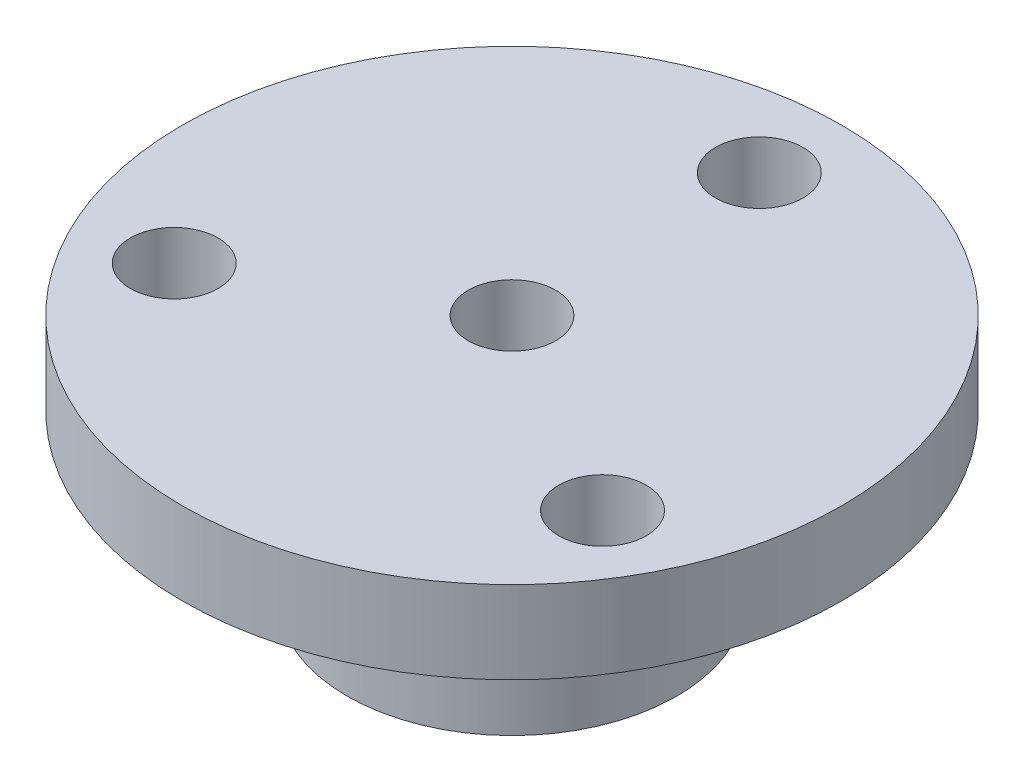
from build123d import *

# Parameters (mm, degrees)
SKETCH1_R                    = 12.7
BOSS_EXTRUDE1_DEPTH          = 12.7
SKETCH2_R                    = 25.4
BOSS_EXTRUDE2_DEPTH          = 6.35
SKETCH3_R                    = 3.3734375
CUT_EXTRUDE1_DEPTH           = 20.05
H_0_266_DIAMETER_HOLE1_D     = 6.7564
H_0_266_DIAMETER_HOLE1_DEPTH = 25.4
H_0_266_DIAMETER_HOLE1_TIP   = 2.029827343


with BuildPart() as part:
    # Sketch1 → Boss-Extrude1 (new body)
    with BuildSketch(Plane(origin=(0, 0, 0), x_dir=(1, 0, 0), z_dir=(0, 1, 0))):
        Circle(SKETCH1_R)
    extrude(amount=BOSS_EXTRUDE1_DEPTH)

    # Sketch2 → Boss-Extrude2 (add)
    with BuildSketch(Plane(origin=(0, 12.7, 0), x_dir=(1, 0, 0), z_dir=(0, 1, 0))):
        Circle(SKETCH2_R)
    extrude(amount=BOSS_EXTRUDE2_DEPTH)

    # Sketch3 → Cut-Extrude1 (cut, through all)
    with BuildSketch(Plane(origin=(0, 19.05, 0), x_dir=(1, 0, 0), z_dir=(0, 1, 0))):
        Circle(SKETCH3_R)
    extrude(amount=-CUT_EXTRUDE1_DEPTH, mode=Mode.SUBTRACT)

    # H (0.266) Diameter Hole1
    with Locations(Plane(origin=(0, 19.05, 0), x_dir=(1, 0, 0), z_dir=(0, 1, 0))):
        with Locations((0, 19.05), (-16.497783942, -9.525), (16.497783942, -9.525)):
            Hole(H_0_266_DIAMETER_HOLE1_D / 2, depth=H_0_266_DIAMETER_HOLE1_DEPTH)
            with Locations((0, 0, -(H_0_266_DIAMETER_HOLE1_DEPTH + H_0_266_DIAMETER_HOLE1_TIP / 2))):  # 118° drill point
                Cone(0, H_0_266_DIAMETER_HOLE1_D / 2, H_0_266_DIAMETER_HOLE1_TIP, mode=Mode.SUBTRACT)

    # Sketch8 → #10 (0.1935) Diameter Hole1 (revolve, cut)
    with BuildSketch(Plane(origin=(0, 6.35, 0), x_dir=(0, 1, 0), z_dir=(1, 0, 0))):
        Polygon((0, 0), (0, 26.876584928), (2.45745, 25.4), (2.45745, 0), align=None)
    revolve(axis=Axis((0, 6.35, -6.35), (0, 0, 1)), mode=Mode.SUBTRACT)


solid = part.part
